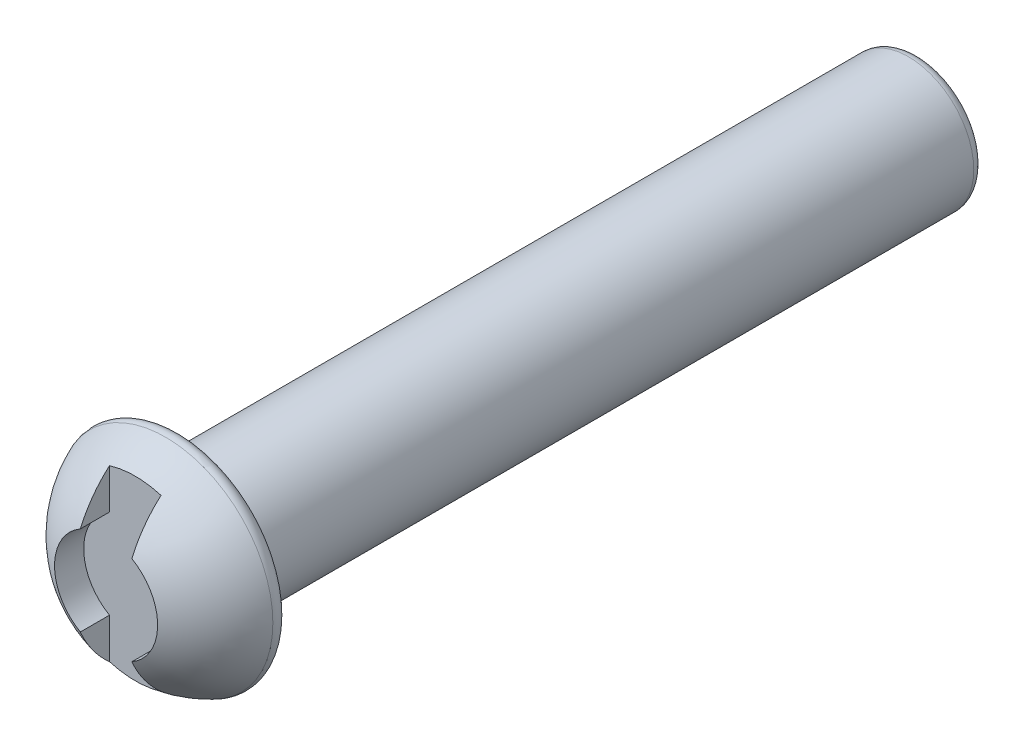
from build123d import *

# Parameters (mm, degrees)
FILLET1_R          = 0.75
CUT_EXTRUDE2_DEPTH = 3


with BuildPart() as part:
    # Sketch1 → Revolve1 (revolve)
    with BuildSketch(Plane(origin=(0, 0, 0), x_dir=(0, 0, -1), z_dir=(1, 0, 0))):
        with BuildLine():
            Line((0, 0), (60, 0))
            Line((60, 0), (60, 4.75))
            Line((60, 4.75), (6.25, 4.75))
            Line((6.25, 4.75), (6.25, 8.15))
            ThreePointArc((6.25, 8.15), (1.742375921, 5.135294539), (0, 0))
        make_face()
    revolve(axis=Axis((0, 0, 0), (0, 0, -1)))

    # Fillet1
    fillet1_edges = [part.edges().sort_by_distance(p)[0] for p in [
        (0, -8.15, -6.25),
        (0, -4.75, -60),
    ]]
    fillet(fillet1_edges, radius=FILLET1_R)

    # Sketch3 → Cut-Extrude2 (cut)
    with BuildSketch(Plane.XY):
        with BuildLine():
            Line((1.875, -3.247595264), (1.875, -8.652971254))
            Line((1.875, -8.652971254), (-1.875, -8.652971254))
            Line((-1.875, -8.652971254), (-1.875, -3.247595264))
            ThreePointArc((-1.875, -3.247595264), (-3.75, 0), (-1.875, 3.247595264))
            Line((-1.875, 3.247595264), (-1.875, 8.652971254))
            Line((-1.875, 8.652971254), (1.875, 8.652971254))
            Line((1.875, 8.652971254), (1.875, 3.247595264))
            ThreePointArc((1.875, 3.247595264), (3.75, 0), (1.875, -3.247595264))
        make_face()
    extrude(amount=-CUT_EXTRUDE2_DEPTH, mode=Mode.SUBTRACT)


solid = part.part
